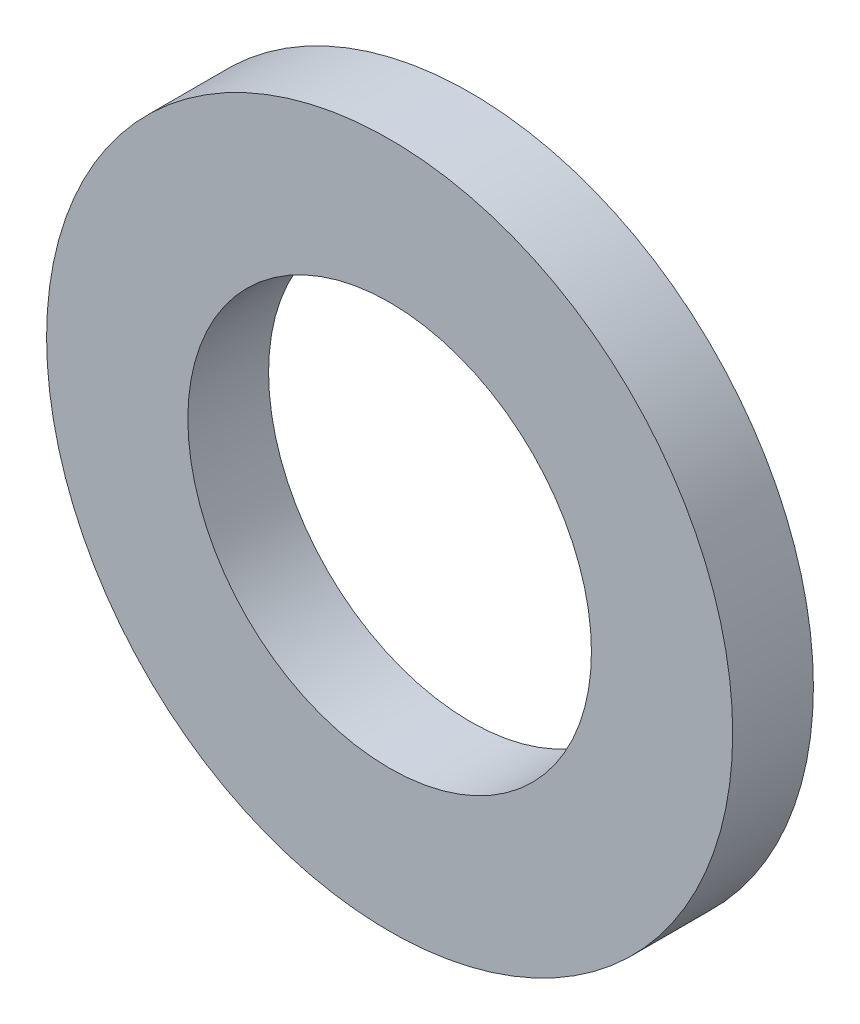
from build123d import *

# Parameters (mm, degrees)
ESQUISSE1_R      = 4.25
ESQUISSE1_R_2    = 2.5
EXTRUSION1_DEPTH = 1


with BuildPart() as part:
    # Esquisse1 → Extrusion1 (new body)
    with BuildSketch(Plane.XY):
        Circle(ESQUISSE1_R)
        Circle(ESQUISSE1_R_2, mode=Mode.SUBTRACT)
    extrude(amount=EXTRUSION1_DEPTH)


solid = part.part
